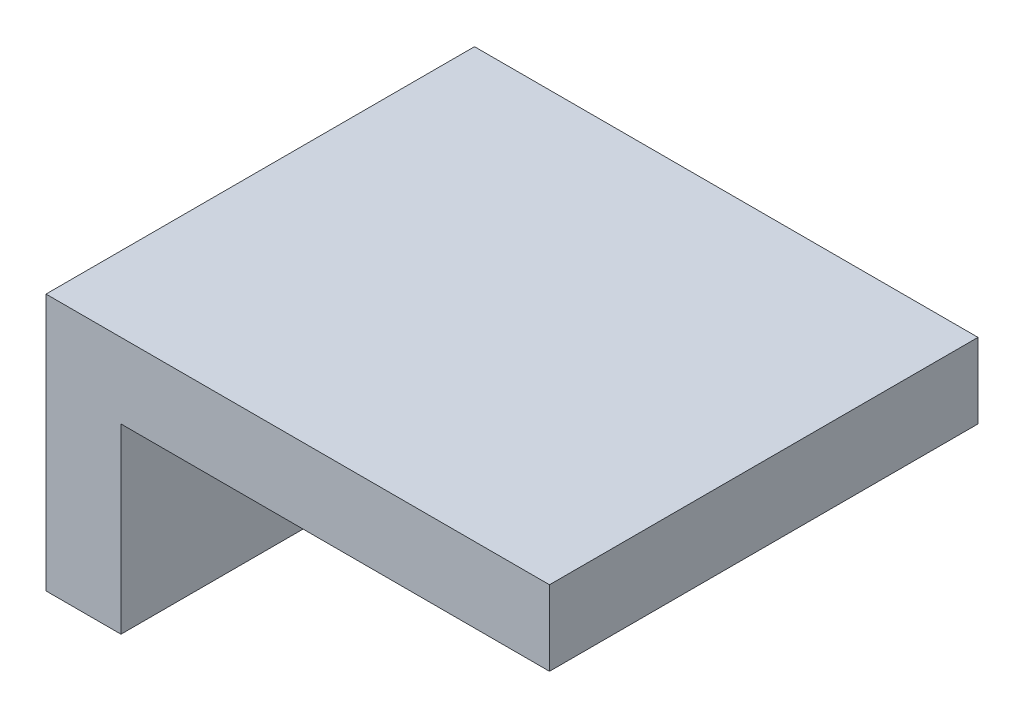
from build123d import *

# Parameters (mm, degrees)
SKETCH1_W           = 40
SKETCH1_H           = 24
BOSS_EXTRUDE1_DEPTH = 7
SKETCH2_W           = 40
SKETCH2_H           = 7
BOSS_EXTRUDE2_DEPTH = 40
SKETCH3_R           = 2.5
CUT_EXTRUDE1_DEPTH  = 14


with BuildPart() as part:
    # Sketch1 → Boss-Extrude1 (new body)
    with BuildSketch(Plane(origin=(0, 0, 0), x_dir=(0, 0, -1), z_dir=(1, 0, 0))):
        Rectangle(SKETCH1_W, SKETCH1_H)
    extrude(amount=BOSS_EXTRUDE1_DEPTH)

    # Sketch2 → Boss-Extrude2 (add)
    with BuildSketch(Plane(origin=(7, 0, 0), x_dir=(0, 0, -1), z_dir=(1, 0, 0))):
        with Locations((0, 8.5)):
            Rectangle(SKETCH2_W, SKETCH2_H)
    extrude(amount=BOSS_EXTRUDE2_DEPTH)

    # Sketch3 → Cut-Extrude1 (cut)
    with BuildSketch(Plane.ZY):
        with Locations((-10.048887394, 0)):
            Circle(SKETCH3_R)
        with Locations((10.048887394, 0)):
            Circle(SKETCH3_R)
    extrude(amount=-CUT_EXTRUDE1_DEPTH, mode=Mode.SUBTRACT)


solid = part.part
